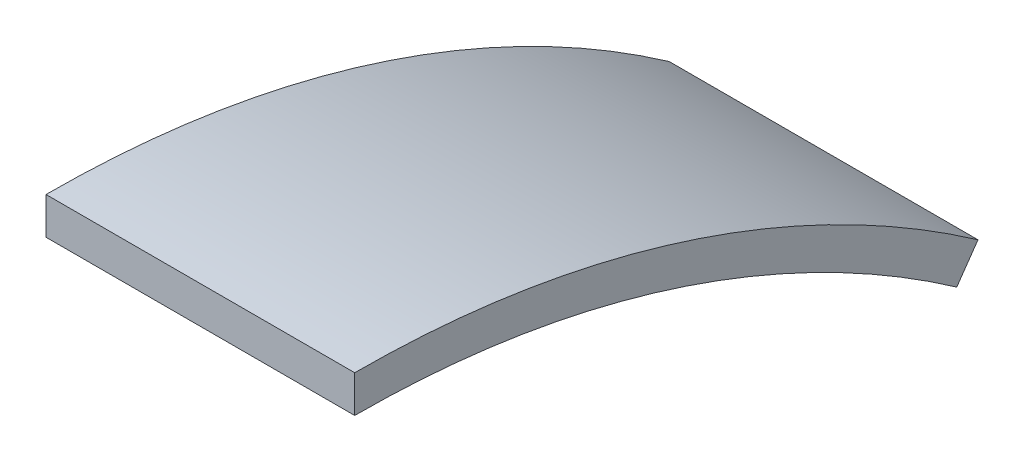
from build123d import *

# Parameters (mm, degrees)
BOSS_EXTRUDE1_DEPTH = 25


with BuildPart() as part:
    # Sketch1 → Boss-Extrude1 (new body)
    with BuildSketch(Plane(origin=(0, 0, 0), x_dir=(0, 0, -1), z_dir=(1, 0, 0))):
        with BuildLine():
            Line((0, 88), (0, 85))
            ThreePointArc((0, 85), (25.559992958, 81.065940814), (48.75399709, 69.627923765))
            Line((48.75399709, 69.627923765), (50.474726399, 72.085379897))
            ThreePointArc((50.474726399, 72.085379897), (26.462110356, 83.927091666), (0, 88))
        make_face()
    extrude(amount=BOSS_EXTRUDE1_DEPTH)


solid = part.part
